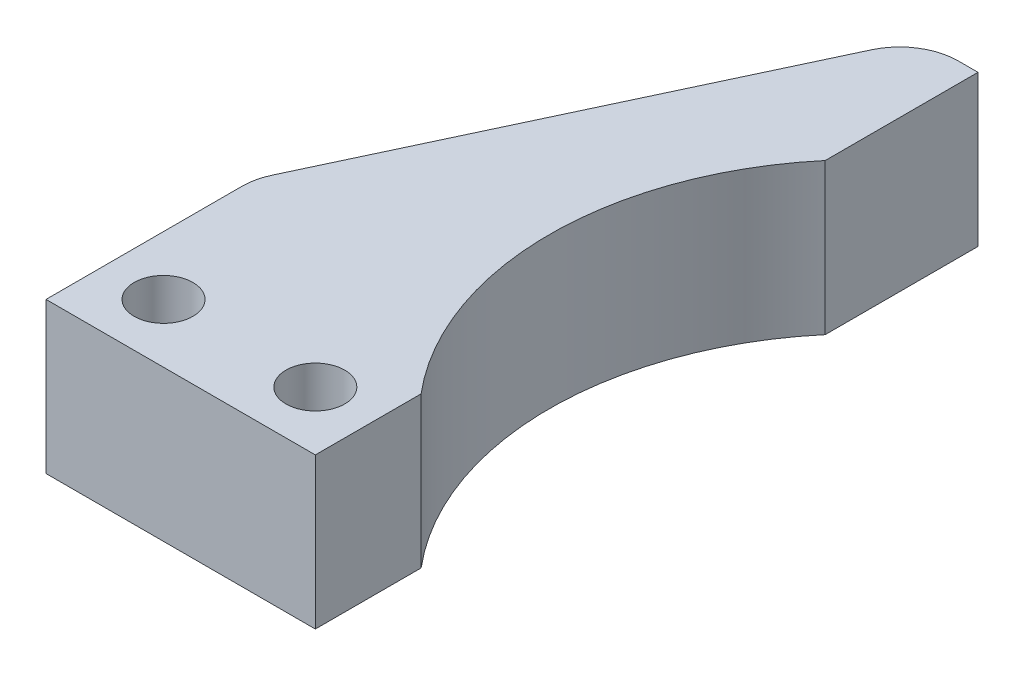
from build123d import *

# Parameters (mm, degrees)
SKETCH1_R           = 1.5
BOSS_EXTRUDE3_DEPTH = 3.85


with BuildPart() as part:
    # Sketch1 → Boss-Extrude3 (new body, symmetric)
    with BuildSketch(Plane(origin=(0, 0, 0), x_dir=(1, 0, 0), z_dir=(0, 1, 0))):
        with BuildLine():
            Line((-13.75, -5.4), (0, -5.4))
            Line((0, -5.4), (0, 0))
            ThreePointArc((0, 0), (-3.769352362, 10.315583277), (0, 20.631166554))
            Line((0, 20.631166554), (0, 28.431166554))
            Line((0, 28.431166554), (-1, 28.431166554))
            ThreePointArc((-1, 28.431166554), (-2.610090465, 27.962492036), (-3.717108681, 26.702905684))
            Line((-3.717108681, 26.702905684), (-13.467108681, 5.87173913))
            ThreePointArc((-13.467108681, 5.87173913), (-13.6784233, 5.251411528), (-13.75, 4.6))
            Line((-13.75, 4.6), (-13.75, -5.4))
        make_face()
        with Locations((-10.75, -2.4)):
            Circle(SKETCH1_R, mode=Mode.SUBTRACT)
        with Locations((-3, -2.4)):
            Circle(SKETCH1_R, mode=Mode.SUBTRACT)
    extrude(amount=BOSS_EXTRUDE3_DEPTH, both=True)


solid = part.part
